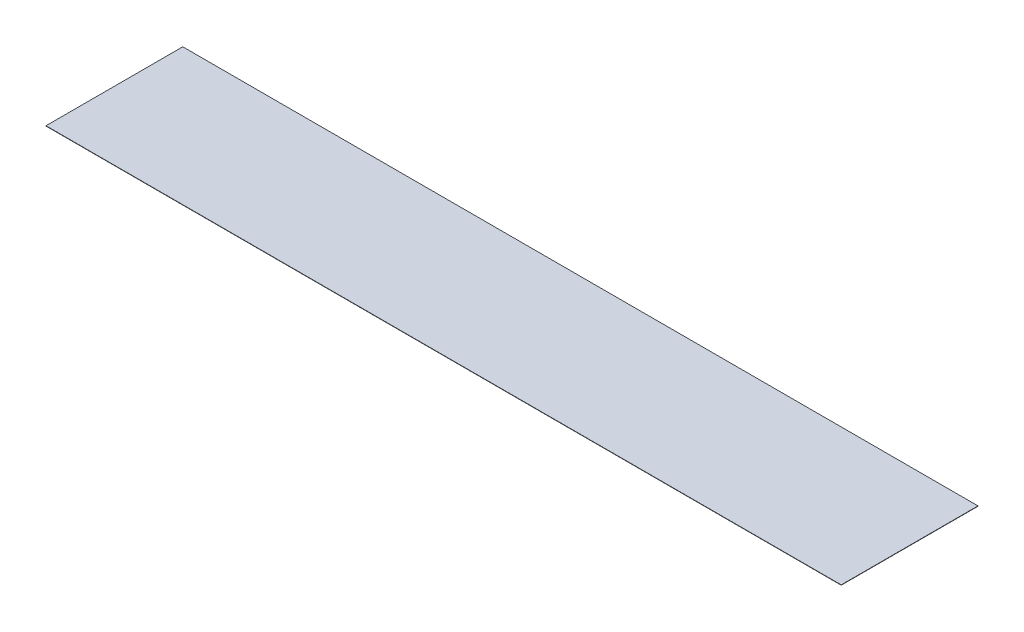
from build123d import *

# Parameters (mm, degrees)
ESQUISSE1_W        = 500
ESQUISSE1_H        = 86
BOSS_EXTRU_1_DEPTH = 0.2


with BuildPart() as part:
    # Esquisse1 → Boss.-Extru.1 (new body)
    with BuildSketch(Plane(origin=(0, 0, 0), x_dir=(1, 0, 0), z_dir=(0, 1, 0))):
        Rectangle(ESQUISSE1_W, ESQUISSE1_H)
    extrude(amount=BOSS_EXTRU_1_DEPTH)


solid = part.part
